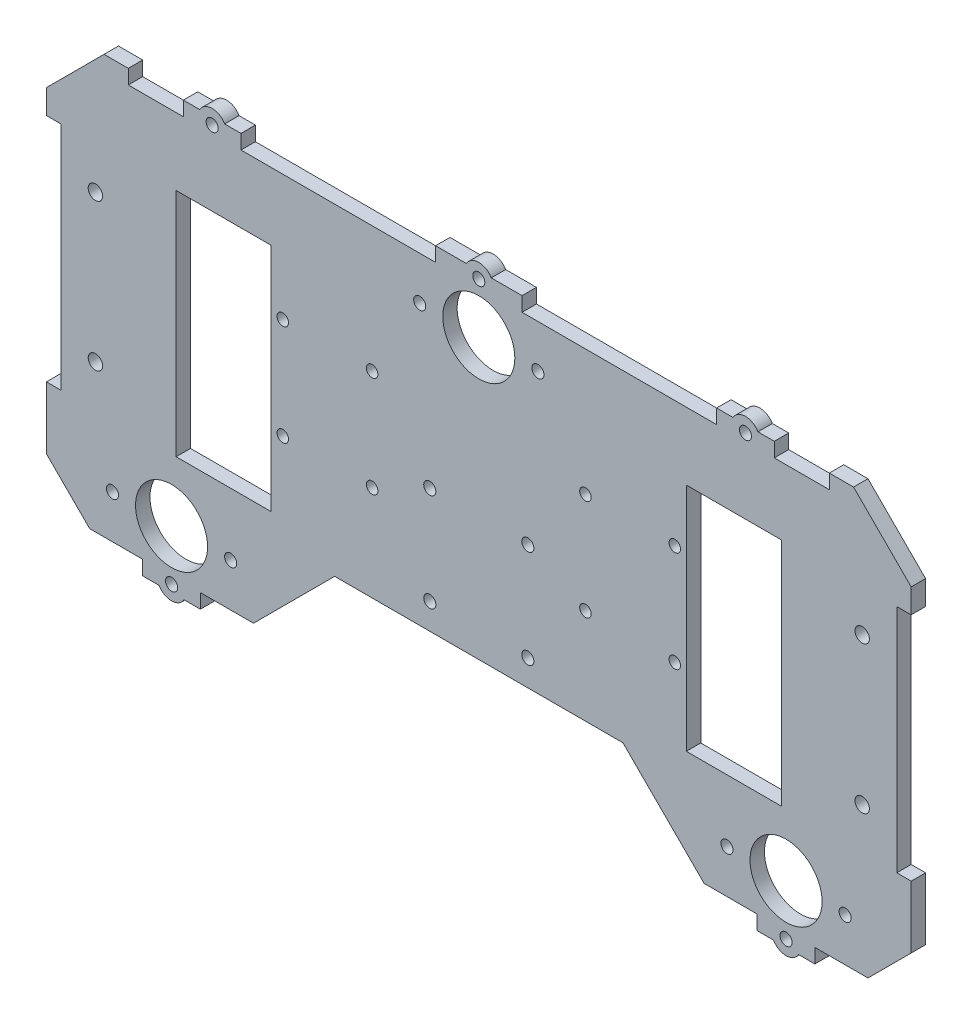
from build123d import *

# Parameters (mm, degrees)
SKETCH1_R           = 12.5
SKETCH1_W           = 33
SKETCH1_H           = 80
BOSS_EXTRUDE1_DEPTH = 5
SKETCH2_R           = 1.6
CUT_EXTRUDE1_DEPTH  = 6
SKETCH4_W           = 5
SKETCH4_H           = 80
CUT_EXTRUDE3_DEPTH  = 6
SKETCH5_R           = 2
CUT_EXTRUDE4_DEPTH  = 6
SKETCH6_R           = 2.5
CUT_EXTRUDE5_DEPTH  = 6
CUT_EXTRUDE7_DEPTH  = 6
SKETCH10_W          = 19.1
SKETCH10_H          = 5
SKETCH10_W_2        = 48.4
CUT_EXTRUDE9_DEPTH  = 6
BOSS_EXTRUDE3_DEPTH = 5
SKETCH12_R          = 2.1
CUT_EXTRUDE10_DEPTH = 5
SKETCH13_R          = 2.1
CUT_EXTRUDE11_DEPTH = 5
SKETCH15_R          = 1.6
BOSS_EXTRUDE4_DEPTH = 5
SKETCH17_R          = 2.1
CUT_EXTRUDE13_DEPTH = 6


with BuildPart() as part:
    # Sketch1 → Boss-Extrude1 (new body)
    with BuildSketch(Plane.XY):
        Polygon((84.001602477, -74.443096951), (130.835354573, -74.443096951), (150.835354573, -54.443096951), (150.835354573, 55.556903049), (130.835354573, 75.556903049), (-129.164645427, 75.556903049), (-149.164645427, 55.556903049), (-149.164645427, -54.443096951), (-129.164645427, -74.443096951), (-82.33089333, -74.443096951), (-49.164645427, -41.276849047), (50.835354573, -41.276849047), align=None)
        with Locations((107.418478525, -54.443096951)):
            Circle(SKETCH1_R, mode=Mode.SUBTRACT)
        with Locations((-105.747769378, -54.443096951)):
            Circle(SKETCH1_R, mode=Mode.SUBTRACT)
        with Locations((0.835354573, 55.556903049)):
            Circle(SKETCH1_R, mode=Mode.SUBTRACT)
        with Locations((89.335354573, 7.157769786)):
            Rectangle(SKETCH1_W, SKETCH1_H, mode=Mode.SUBTRACT)
        with Locations((-87.664645427, 7.157769786)):
            Rectangle(SKETCH1_W, SKETCH1_H, mode=Mode.SUBTRACT)
    extrude(amount=BOSS_EXTRUDE1_DEPTH)

    # Sketch2 → Cut-Extrude1 (cut, through all)
    with BuildSketch(Plane.XY.offset(5)):
        with Locations((17.335354573, -3.276849047)):
            Circle(SKETCH2_R)
        with Locations((17.335354573, -37.276849047)):
            Circle(SKETCH2_R)
        with Locations((-16.664645427, -37.276849047)):
            Circle(SKETCH2_R)
        with Locations((-16.664645427, -3.276849047)):
            Circle(SKETCH2_R)
    extrude(amount=-CUT_EXTRUDE1_DEPTH, mode=Mode.SUBTRACT)

    # Sketch4 → Cut-Extrude3 (cut, through all)
    with BuildSketch(Plane.XY.offset(5)):
        with Locations((148.335354573, 7.157769786)):
            Rectangle(SKETCH4_W, SKETCH4_H)
        with Locations((-146.664645427, 7.157769786)):
            Rectangle(SKETCH4_W, SKETCH4_H)
    extrude(amount=-CUT_EXTRUDE3_DEPTH, mode=Mode.SUBTRACT)

    # Sketch5 → Cut-Extrude4 (cut, through all)
    with BuildSketch(Plane.XY.offset(5)):
        with Locations((-67.164645427, -8.117475471)):
            Circle(SKETCH5_R)
        with Locations((-36.164645427, -8.117475471)):
            Circle(SKETCH5_R)
        with Locations((-36.164645427, 26.882524529)):
            Circle(SKETCH5_R)
        with Locations((-67.164645427, 26.882524529)):
            Circle(SKETCH5_R)
        with Locations((68.835354573, 26.882524529)):
            Circle(SKETCH5_R)
        with Locations((37.835354573, 26.882524529)):
            Circle(SKETCH5_R)
        with Locations((37.835354573, -8.117475471)):
            Circle(SKETCH5_R)
        with Locations((68.835354573, -8.117475471)):
            Circle(SKETCH5_R)
    extrude(amount=-CUT_EXTRUDE4_DEPTH, mode=Mode.SUBTRACT)

    # Sketch6 → Cut-Extrude5 (cut, through all)
    with BuildSketch(Plane.XY.offset(5)):
        with Locations((133.835354573, -18.342230214)):
            Circle(SKETCH6_R)
        with Locations((133.835354573, 32.657769786)):
            Circle(SKETCH6_R)
        with Locations((-132.164645427, 32.657769786)):
            Circle(SKETCH6_R)
        with Locations((-132.164645427, -18.342230214)):
            Circle(SKETCH6_R)
    extrude(amount=-CUT_EXTRUDE5_DEPTH, mode=Mode.SUBTRACT)

    # Sketch7 → Cut-Extrude7 (cut, through all)
    with BuildSketch(Plane.XY.offset(5)):
        Polygon((-115.747769378, -69.443096951), (-134.164645427, -69.443096951), (-129.164645427, -74.443096951), (-115.747769378, -74.443096951), align=None)
        Polygon((-95.747769378, -74.443096951), (-95.747769378, -69.443096951), (-77.33089333, -69.443096951), (-82.33089333, -74.443096951), align=None)
        Polygon((97.418478525, -74.443096951), (84.001602477, -74.443096951), (79.001602477, -69.443096951), (97.418478525, -69.443096951), align=None)
        Polygon((130.835354573, -74.443096951), (117.418478525, -74.443096951), (117.418478525, -69.443096951), (135.835354573, -69.443096951), align=None)
    extrude(amount=-CUT_EXTRUDE7_DEPTH, mode=Mode.SUBTRACT)

    # Sketch10 → Cut-Extrude9 (cut, through all)
    with BuildSketch(Plane.XY.offset(5)):
        with Locations((-111.214645427, 73.056903049)):
            Rectangle(SKETCH10_W, SKETCH10_H)
        with Locations((-72.114645427, 73.056903049)):
            Rectangle(SKETCH10_W, SKETCH10_H)
        with Locations((-38.364645427, 73.056903049)):
            Rectangle(SKETCH10_W_2, SKETCH10_H)
        Polygon((83.335354573, 75.556903049), (83.335354573, 70.556903049), (64.235354573, 70.556903049), (15.835354573, 70.556903049), (15.835354573, 75.556903049), (64.235354573, 75.556903049), align=None)
        with Locations((112.885354573, 73.056903049)):
            Rectangle(SKETCH10_W, SKETCH10_H)
    extrude(amount=-CUT_EXTRUDE9_DEPTH, mode=Mode.SUBTRACT)

    # Sketch11 → Boss-Extrude3 (add)
    with BuildSketch(Plane.XY.offset(5)):
        with BuildLine():
            Line((103.088351506, -74.443096951), (111.748605544, -74.443096951))
            ThreePointArc((111.748605544, -74.443096951), (107.418478525, -76.943096951), (103.088351506, -74.443096951))
        make_face()
        with BuildLine():
            Line((-110.077896397, -74.443096951), (-101.417642359, -74.443096951))
            ThreePointArc((-101.417642359, -74.443096951), (-105.747769378, -76.943096951), (-110.077896397, -74.443096951))
        make_face()
        with BuildLine():
            Line((97.665481592, 75.556903049), (89.005227555, 75.556903049))
            ThreePointArc((89.005227555, 75.556903049), (93.335354573, 78.056903049), (97.665481592, 75.556903049))
        make_face()
        with BuildLine():
            Line((5.165481592, 75.556903049), (-3.494772445, 75.556903049))
            ThreePointArc((-3.494772445, 75.556903049), (0.835354573, 78.056903049), (5.165481592, 75.556903049))
        make_face()
        with BuildLine():
            Line((-87.334518408, 75.556903049), (-95.994772445, 75.556903049))
            ThreePointArc((-95.994772445, 75.556903049), (-91.664645427, 78.056903049), (-87.334518408, 75.556903049))
        make_face()
    extrude(amount=-BOSS_EXTRUDE3_DEPTH)

    # Sketch12 → Cut-Extrude10 (cut)
    with BuildSketch(Plane.XY.offset(5)):
        with Locations((107.418478525, -71.943096951)):
            Circle(SKETCH12_R)
        with Locations((-105.747769378, -71.943096951)):
            Circle(SKETCH12_R)
        with Locations((93.335354573, 73.056903049)):
            Circle(SKETCH12_R)
        with Locations((0.835354573, 73.056903049)):
            Circle(SKETCH12_R)
        with Locations((-91.664645427, 73.056903049)):
            Circle(SKETCH12_R)
    extrude(amount=-CUT_EXTRUDE10_DEPTH, mode=Mode.SUBTRACT)

    # Sketch13 → Cut-Extrude11 (cut)
    with BuildSketch(Plane.XY.offset(5)):
        with Locations((-19.664645427, 55.556903049)):
            Circle(SKETCH13_R)
        with Locations((21.335354573, 55.556903049)):
            Circle(SKETCH13_R)
        with Locations((-126.247769378, -54.443096951)):
            Circle(SKETCH13_R)
        with Locations((-85.247769378, -54.443096951)):
            Circle(SKETCH13_R)
        with Locations((86.918478525, -54.443096951)):
            Circle(SKETCH13_R)
        with Locations((127.918478525, -54.443096951)):
            Circle(SKETCH13_R)
    extrude(amount=-CUT_EXTRUDE11_DEPTH, mode=Mode.SUBTRACT)

    # Sketch15 → Boss-Extrude4 (add)
    with BuildSketch(Plane(origin=(0, 0, 0), x_dir=(-1, 0, 0), z_dir=(0, 0, -1))):
        with Locations((16.664645427, -37.276849047)):
            Circle(SKETCH15_R)
        with Locations((16.664645427, -3.276849047)):
            Circle(SKETCH15_R)
        with Locations((-17.335354573, -37.276849047)):
            Circle(SKETCH15_R)
        with Locations((-17.335354573, -3.276849047)):
            Circle(SKETCH15_R)
    extrude(amount=-BOSS_EXTRUDE4_DEPTH)

    # Sketch17 → Cut-Extrude13 (cut, through all)
    with BuildSketch(Plane.XY.offset(5)):
        with Locations((-16.164645427, 1.723150953)):
            Circle(SKETCH17_R)
        with Locations((17.835354573, 1.723150953)):
            Circle(SKETCH17_R)
        with Locations((17.835354573, -32.276849047)):
            Circle(SKETCH17_R)
        with Locations((-16.164645427, -32.276849047)):
            Circle(SKETCH17_R)
    extrude(amount=-CUT_EXTRUDE13_DEPTH, mode=Mode.SUBTRACT)


solid = part.part
